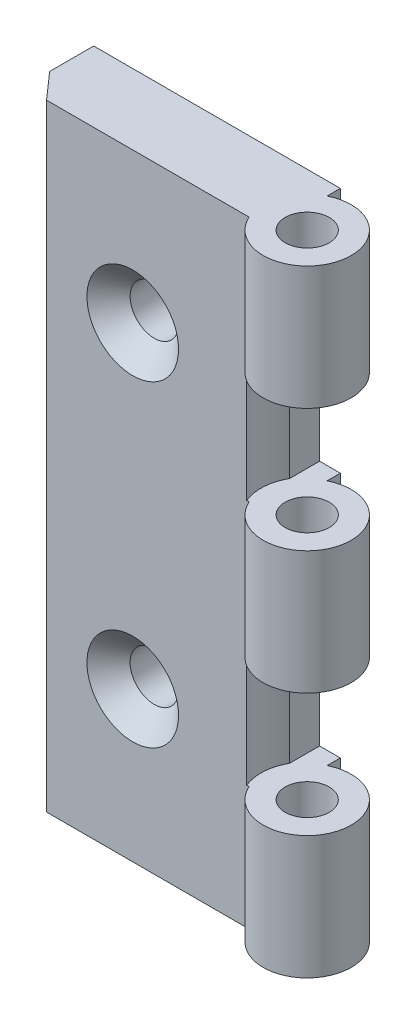
from build123d import *

# Parameters (mm, degrees)
SKETCH1_R                                       = 2.5
BOSS_EXTRUDE1_DEPTH                             = 35
SKETCH2_W                                       = 19.147849822
SKETCH2_H                                       = 14
CUT_EXTRUDE1_DEPTH                              = 11.980294351
CUT_EXTRUDE1_DEPTH_BACK                         = 1
CSK_FOR_M5_FLAT_HEAD_MACHINE_SCREW1_D           = 5.5
CSK_FOR_M5_FLAT_HEAD_MACHINE_SCREW1_DEPTH       = 13.347633298
CSK_FOR_M5_FLAT_HEAD_MACHINE_SCREW1_CSINK_D     = 10.4
CSK_FOR_M5_FLAT_HEAD_MACHINE_SCREW1_CSINK_ANGLE = 90
CSK_FOR_M5_FLAT_HEAD_MACHINE_SCREW1_TIP         = 1.652366702
CUT_EXTRUDE2_START                              = -14
SKETCH6_R                                       = 5.25
CUT_EXTRUDE2_DEPTH                              = 14
CUT_EXTRUDE3_START                              = -42
SKETCH6_2_R                                     = 5.25
CUT_EXTRUDE3_DEPTH                              = 14


with BuildPart() as part:
    # Sketch1 → Boss-Extrude1 (new body, symmetric)
    with BuildSketch(Plane(origin=(0, 0, 0), x_dir=(1, 0, 0), z_dir=(0, 1, 0))):
        with BuildLine():
            Line((0, 0), (28, 0))
            Line((28, 0), (28, -1.5))
            ThreePointArc((28, -1.5), (34.920820135, -7.683011565), (25.645751311, -8))
            Line((25.645751311, -8), (2.645751311, -8))
            Line((2.645751311, -8), (0, -5))
            Line((0, -5), (0, 0))
        make_face()
        with Locations((30.219676222, -5.980294351)):
            Circle(SKETCH1_R, mode=Mode.SUBTRACT)
    extrude(amount=BOSS_EXTRUDE1_DEPTH, both=True)

    # Sketch2 → Cut-Extrude1 (cut, two sides)
    with BuildSketch(Plane.XY) as cut_extrude1_sk:
        with Locations((35.219676222, 14)):
            Rectangle(SKETCH2_W, SKETCH2_H)
        with Locations((35.219676222, -14)):
            Rectangle(SKETCH2_W, SKETCH2_H)
    extrude(amount=CUT_EXTRUDE1_DEPTH, mode=Mode.SUBTRACT)
    extrude(cut_extrude1_sk.sketch, amount=-CUT_EXTRUDE1_DEPTH_BACK, mode=Mode.SUBTRACT)

    # CSK for M5 Flat Head Machine Screw1
    with Locations(Plane.XY.offset(8)):
        with Locations((12.432713767, 18), (12.432713767, -18)):
            CounterSinkHole(CSK_FOR_M5_FLAT_HEAD_MACHINE_SCREW1_D / 2, CSK_FOR_M5_FLAT_HEAD_MACHINE_SCREW1_CSINK_D / 2, depth=CSK_FOR_M5_FLAT_HEAD_MACHINE_SCREW1_DEPTH, counter_sink_angle=CSK_FOR_M5_FLAT_HEAD_MACHINE_SCREW1_CSINK_ANGLE)
            with Locations((0, 0, -(CSK_FOR_M5_FLAT_HEAD_MACHINE_SCREW1_DEPTH + CSK_FOR_M5_FLAT_HEAD_MACHINE_SCREW1_TIP / 2))):  # 118° drill point
                Cone(0, CSK_FOR_M5_FLAT_HEAD_MACHINE_SCREW1_D / 2, CSK_FOR_M5_FLAT_HEAD_MACHINE_SCREW1_TIP, mode=Mode.SUBTRACT)

    # Sketch6 → Cut-Extrude2 (cut)
    with BuildSketch(Plane(origin=(0, 35, 0), x_dir=(1, 0, 0), z_dir=(0, 1, 0)).offset(CUT_EXTRUDE2_START)):
        with Locations((30.219676222, -5.980294351)):
            Circle(SKETCH6_R)
    extrude(amount=-CUT_EXTRUDE2_DEPTH, mode=Mode.SUBTRACT)

    # Sketch6_2 → Cut-Extrude3 (cut)
    with BuildSketch(Plane(origin=(0, 35, 0), x_dir=(1, 0, 0), z_dir=(0, 1, 0)).offset(CUT_EXTRUDE3_START)):
        with Locations((30.219676222, -5.980294351)):
            Circle(SKETCH6_2_R)
    extrude(amount=-CUT_EXTRUDE3_DEPTH, mode=Mode.SUBTRACT)


solid = part.part
